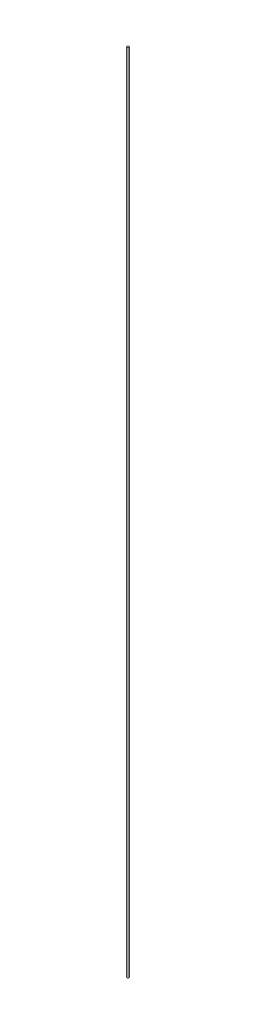
from build123d import *

# Parameters (mm, degrees)
SKETCH2_R           = 1.27
BOSS_EXTRUDE3_DEPTH = 1136.65


with BuildPart() as part:
    # Sketch2 → Boss-Extrude3 (new body)
    with BuildSketch(Plane(origin=(0, 0, 0), x_dir=(1, 0, 0), z_dir=(0, 1, 0))):
        Circle(SKETCH2_R)
    extrude(amount=BOSS_EXTRUDE3_DEPTH)


solid = part.part
